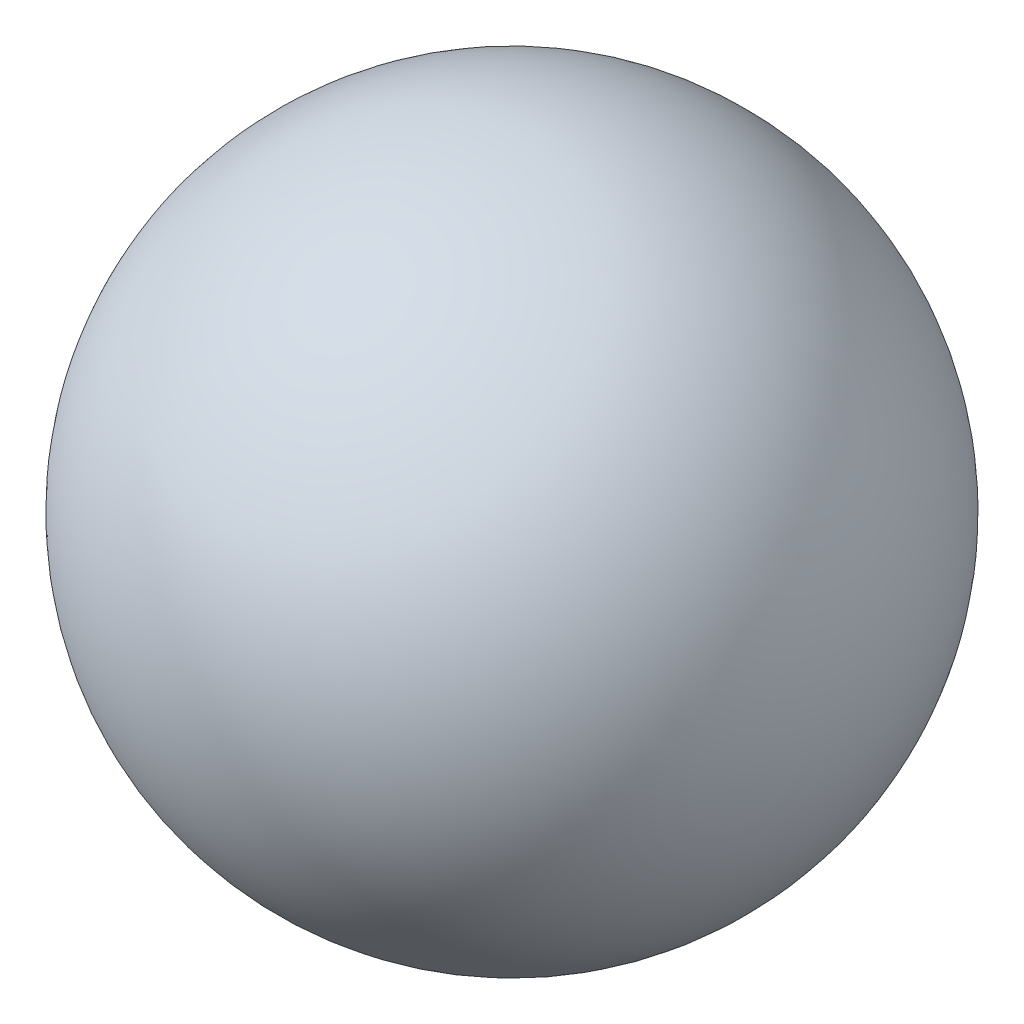
from build123d import *


with BuildPart() as part:
    # Sketch1 → Revolve1 (revolve)
    with BuildSketch(Plane.XY):
        with BuildLine():
            Line((-9, 0), (9, 0))
            ThreePointArc((9, 0), (0, 9), (-9, 0))
        make_face()
    revolve(axis=Axis((-9, 0, 0), (1, 0, 0)))


solid = part.part
